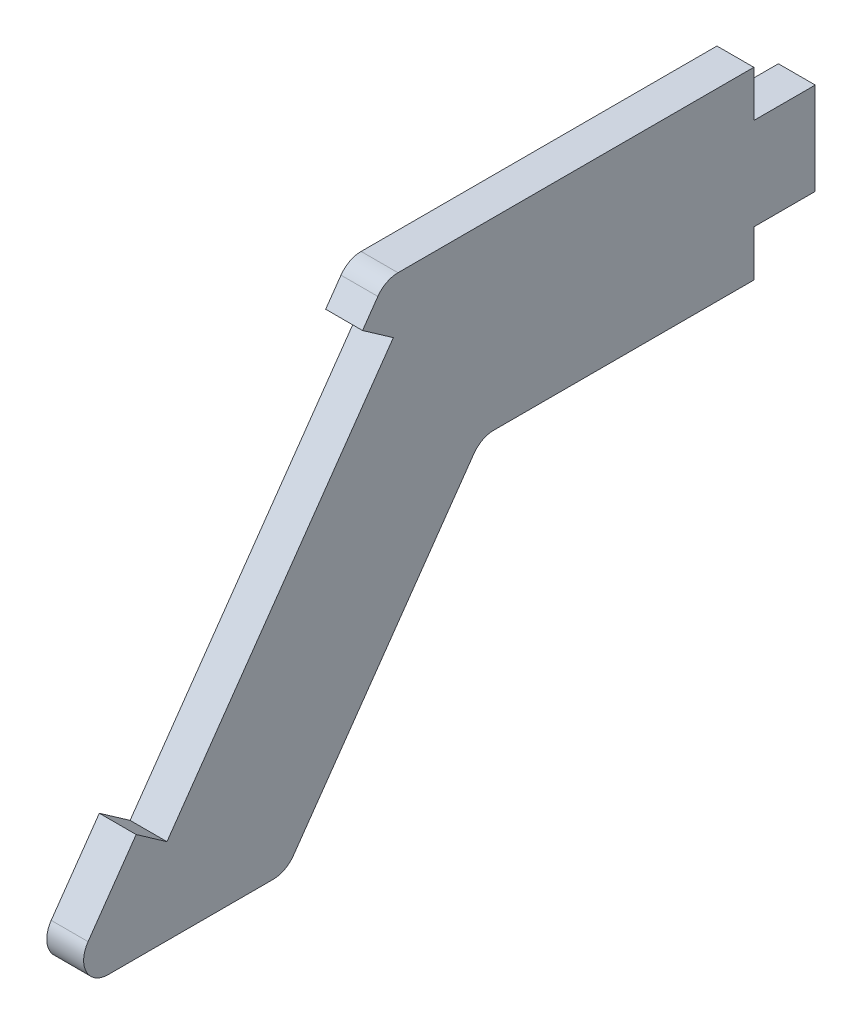
from build123d import *

# Parameters (mm, degrees)
BOSS_EXTRUDE1_DEPTH = 3
CUT_EXTRUDE1_DEPTH  = 3


with BuildPart() as part:
    # Sketch2 → Boss-Extrude1 (new body)
    with BuildSketch(Plane(origin=(0, 0, 0), x_dir=(0, 0, -1), z_dir=(1, 0, 0))):
        with BuildLine():
            Line((0, -99.604434048), (-28.958865899, -99.604434048))
            ThreePointArc((-28.958865899, -99.604434048), (-29.882363125, -99.830412381), (-30.597169987, -100.457281175))
            Line((-30.597169987, -100.457281175), (-54.180855907, -134.138275212))
            ThreePointArc((-54.180855907, -134.138275212), (-54.316573485, -136.208925312), (-52.542551818, -137.285428085))
            Line((-52.542551818, -137.285428085), (-39.114031342, -137.285428085))
            ThreePointArc((-39.114031342, -137.285428085), (-38.190534115, -137.059449751), (-37.475727253, -136.432580958))
            Line((-37.475727253, -136.432580958), (-22.788664229, -115.457281175))
            ThreePointArc((-22.788664229, -115.457281175), (-22.073857367, -114.830412381), (-21.150360141, -114.604434048))
            Line((-21.150360141, -114.604434048), (0, -114.604434048))
            Line((0, -114.604434048), (0, -110.854434048))
            Line((0, -110.854434048), (5, -110.854434048))
            Line((5, -110.854434048), (5, -103.354434048))
            Line((5, -103.354434048), (0, -103.354434048))
            Line((0, -103.354434048), (0, -99.604434048))
        make_face()
    extrude(amount=BOSS_EXTRUDE1_DEPTH)

    # Sketch3 → Cut-Extrude1 (cut)
    with BuildSketch(Plane.ZY):
        Polygon((50.2661846, -128.547545189), (47.759579345, -130.302689084), (29.336304209, -103.991525421), (31.842909464, -102.236381526), align=None)
    extrude(amount=-CUT_EXTRUDE1_DEPTH, mode=Mode.SUBTRACT)


solid = part.part
